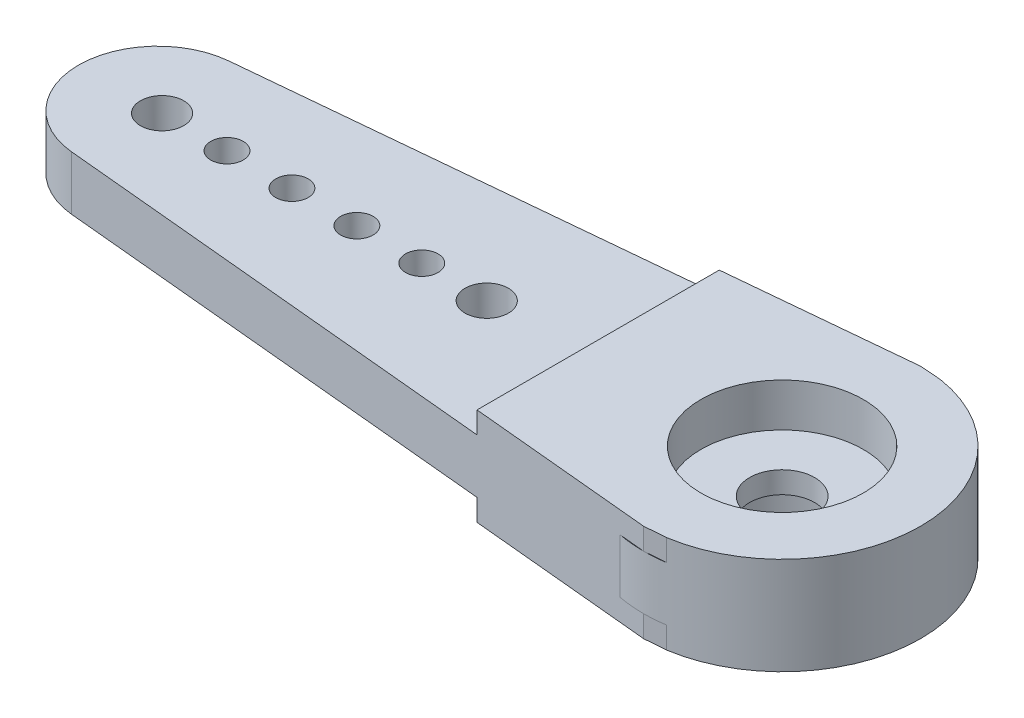
from build123d import *

# Parameters (mm, degrees)
EXTRUDE_1_DEPTH      = 2.5
EXTRUDE_2_DEPTH      = 1
EXTRUDE_2_DEPTH_BACK = 3.5
SKETCH_4_R           = 1.5
CUT_EXTRUDE_1_DEPTH  = 14.5
SKETCH_7_R           = 1
SKETCH_7_R_2         = 0.75
CUT_EXTRUDE_4_DEPTH  = 3
SKETCH_8_R           = 4.75
EXTRUDE_3_DEPTH      = 1.5
EXTRUDE_3_TAPER      = 23
SKETCH_9_R           = 3.25
CUT_EXTRUDE_5_DEPTH  = 3
SKETCH_10_R          = 3.75
CUT_EXTRUDE_6_DEPTH  = 2


with BuildPart() as part:
    # ｽｹｯﾁ1 → ﾎﾞｽ - 押し出し1 (new body)
    with BuildSketch(Plane(origin=(0, 0, 0), x_dir=(1, 0, 0), z_dir=(0, 1, 0))):
        with BuildLine():
            Line((27.647942003, 6.286100267), (-0.344309679, 3.633724101))
            ThreePointArc((-0.344309679, 3.633724101), (-3.65, 0), (-0.344309679, -3.633724101))
            Line((-0.344309679, -3.633724101), (27.647942003, -6.286100267))
            ThreePointArc((27.647942003, -6.286100267), (35.25, 0), (27.647942003, 6.286100267))
        make_face()
    extrude(amount=EXTRUDE_1_DEPTH)

    # ｽｹｯﾁ2 → ﾎﾞｽ - 押し出し2 (add, two sides)
    with BuildSketch(Plane(origin=(0, 2.5, 0), x_dir=(1, 0, 0), z_dir=(0, 1, 0))) as extrude_2_sk:
        with BuildLine():
            Line((27.647942003, 6.286100267), (20.35, 5.594591501))
            Line((20.35, 5.594591501), (20.35, -5.594591501))
            Line((20.35, -5.594591501), (27.647942003, -6.286100267))
            Line((27.647942003, -6.286100267), (28.85, -6.4))
            Line((28.85, -6.4), (29.836801685, -6.323466014))
            ThreePointArc((29.836801685, -6.323466014), (35.25, 0), (29.836801685, 6.323466014))
            Line((29.836801685, 6.323466014), (28.85, 6.4))
            Line((28.85, 6.4), (27.647942003, 6.286100267))
        make_face()
    extrude(amount=EXTRUDE_2_DEPTH)
    extrude(extrude_2_sk.sketch, amount=-EXTRUDE_2_DEPTH_BACK)

    # ｽｹｯﾁ4 → ｶｯﾄ - 押し出し1 (cut)
    with BuildSketch(Plane(origin=(0, 3.5, 0), x_dir=(1, 0, 0), z_dir=(0, 1, 0))):
        with Locations(Location((28.85, 0, 0), (0, 0, 270))):
            Circle(SKETCH_4_R)
    extrude(amount=-CUT_EXTRUDE_1_DEPTH, mode=Mode.SUBTRACT)

    # ｽｹｯﾁ7 → ｶｯﾄ - 押し出し4 (cut)
    with BuildSketch(Plane(origin=(0, 2.5, 0), x_dir=(1, 0, 0), z_dir=(0, 1, 0))):
        with Locations((57.7, 0)):
            Circle(SKETCH_7_R)
        with Locations(Location((15.204795613, 0, 0), (0, 0, 270))):
            Circle(SKETCH_7_R)
        with Locations((54.7, 0)):
            Circle(SKETCH_7_R)
        with Locations((51.7, 0)):
            Circle(SKETCH_7_R)
        with Locations((48.7, 0)):
            Circle(SKETCH_7_R)
        with Locations((45.7, 0)):
            Circle(SKETCH_7_R)
        with Locations(Location((12.204795613, 0, 0), (0, 0, 270))):
            Circle(SKETCH_7_R_2)
        with Locations(Location((9.204795613, 0, 0), (0, 0, 270))):
            Circle(SKETCH_7_R_2)
        with Locations(Location((6.204795613, 0, 0), (0, 0, 270))):
            Circle(SKETCH_7_R_2)
        with Locations(Location((3.204795613, 0, 0), (0, 0, 270))):
            Circle(SKETCH_7_R_2)
        with Locations(Location((0.204795613, 0, 0), (0, 0, 270))):
            Circle(SKETCH_7_R)
    extrude(amount=-CUT_EXTRUDE_4_DEPTH, mode=Mode.SUBTRACT)

    # ｽｹｯﾁ8 → ﾎﾞｽ - 押し出し3 (add)
    with BuildSketch(Plane(origin=(0, -1, 0), x_dir=(-1, 0, 0), z_dir=(0, -1, 0))):
        with Locations((-28.85, 0)):
            Circle(SKETCH_8_R)
    extrude(amount=EXTRUDE_3_DEPTH, taper=EXTRUDE_3_TAPER)

    # ｽｹｯﾁ9 → ｶｯﾄ - 押し出し5 (cut)
    with BuildSketch(Plane(origin=(0, -2.5, 0), x_dir=(-1, 0, 0), z_dir=(0, -1, 0))):
        with Locations(Location((-28.85, 0, 0), (0, 0, 90))):
            Circle(SKETCH_9_R)
    extrude(amount=-CUT_EXTRUDE_5_DEPTH, mode=Mode.SUBTRACT)

    # ｽｹｯﾁ10 → ｶｯﾄ - 押し出し6 (cut)
    with BuildSketch(Plane(origin=(0, 3.5, 0), x_dir=(1, 0, 0), z_dir=(0, 1, 0))):
        with Locations(Location((28.85, 0, 0), (0, 0, 270))):
            Circle(SKETCH_10_R)
    extrude(amount=-CUT_EXTRUDE_6_DEPTH, mode=Mode.SUBTRACT)


solid = part.part
